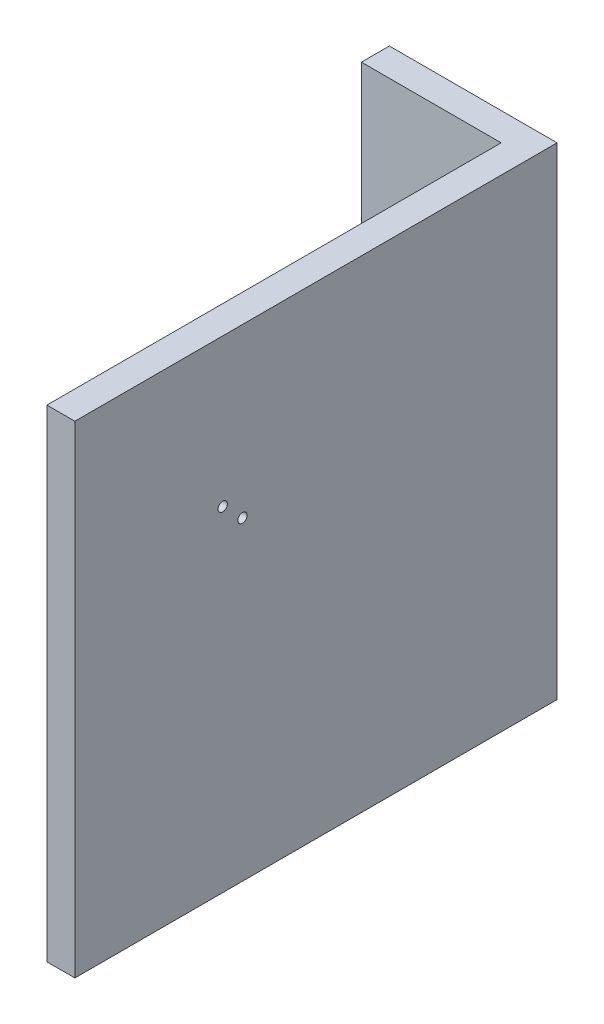
from build123d import *

# Parameters (mm, degrees)
SKETCH1_W           = 344.997499296
SKETCH1_H           = 344.997499295
BOSS_EXTRUDE1_DEPTH = 20
SKETCH2_R           = 3.349999998
CUT_EXTRUDE1_DEPTH  = 21
SKETCH3_W           = 20
SKETCH3_H           = 344.997499295
BOSS_EXTRUDE2_DEPTH = 100


with BuildPart() as part:
    # Sketch1 → Boss-Extrude1 (new body)
    with BuildSketch(Plane.ZY.offset(23098.612597115)):
        with Locations((40779.406254132, 6851.802826482)):
            Rectangle(SKETCH1_W, SKETCH1_H)
    extrude(amount=BOSS_EXTRUDE1_DEPTH)

    # Sketch2 → Cut-Extrude1 (cut, through all)
    with BuildSketch(Plane.ZY.offset(23118.612597115)):
        with Locations((40846.136031778, 6918.532604128)):
            Circle(SKETCH2_R)
        with Locations((40831.993896154, 6904.390468504)):
            Circle(SKETCH2_R)
    extrude(amount=-CUT_EXTRUDE1_DEPTH, mode=Mode.SUBTRACT)

    # Sketch3 → Boss-Extrude2 (add)
    with BuildSketch(Plane.ZY.offset(23118.612597115)):
        with Locations((40616.907504484, 6851.802826482)):
            Rectangle(SKETCH3_W, SKETCH3_H)
    extrude(amount=BOSS_EXTRUDE2_DEPTH)


solid = part.part
